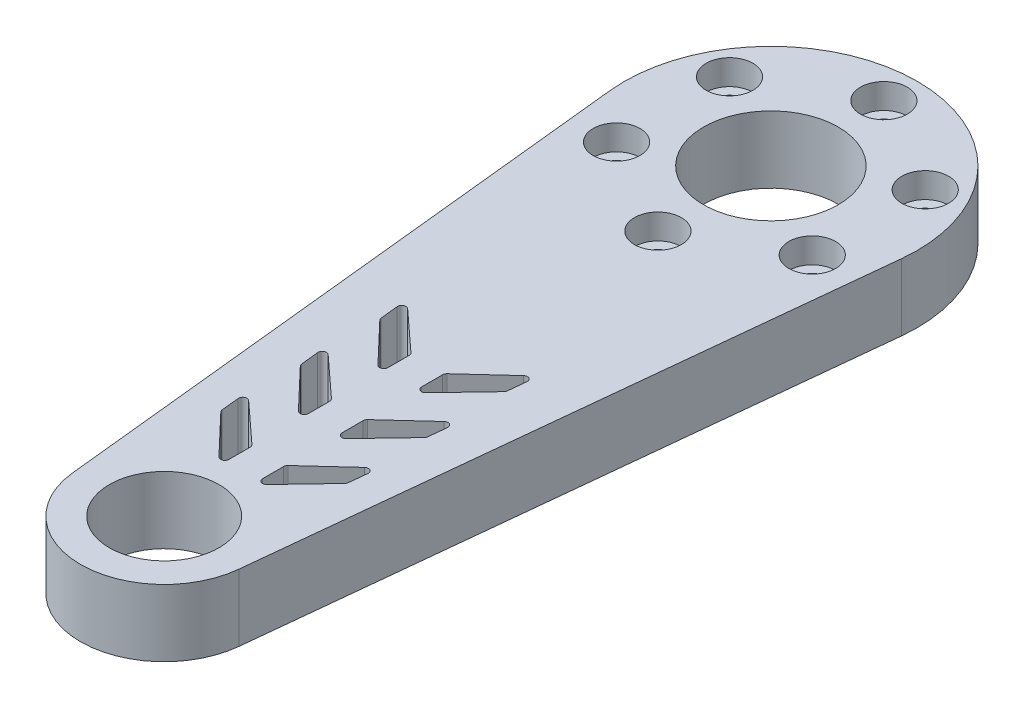
from build123d import *

# Parameters (mm, degrees)
EXTRUDE_1_DEPTH                = 8
CUT_EXTRUDE_1_DEPTH            = 9
CUT_EXTRUDE_2_DEPTH            = 9
CUT_EXTRUDE_3_DEPTH            = 9
CUT_EXTRUDE_4_DEPTH            = 9
CUT_EXTRUDE_5_DEPTH            = 9
CUT_EXTRUDE_6_DEPTH            = 9
HOLE_WIZARD_16_0_16_1_D        = 16.1
HOLE_WIZARD_16_0_16_1_DEPTH    = 8
HOLE_WIZARD_13_0_13_1_D        = 13.1
HOLE_WIZARD_13_0_13_1_DEPTH    = 8
HOLE_WIZARD_M2_5_1_D           = 3.1
HOLE_WIZARD_M2_5_1_DEPTH       = 8
HOLE_WIZARD_M2_5_1_CBORE_D     = 5.6
HOLE_WIZARD_M2_5_1_CBORE_DEPTH = 3
FILLET_1_R                     = 0.5


with BuildPart() as part:
    # 草图1 → 凸台-拉伸1 (new body)
    with BuildSketch(Plane(origin=(0, 4, 0), x_dir=(1, 0, 0), z_dir=(0, 1, 0))):
        with BuildLine():
            Line((-17.406109606, -1.810344828), (-9.946348346, -73.534482759))
            ThreePointArc((-9.946348346, -73.534482759), (0, -82.5), (9.946348346, -73.534482759))
            Line((9.946348346, -73.534482759), (17.406109606, -1.810344828))
            ThreePointArc((17.406109606, -1.810344828), (0, 17.5), (-17.406109606, -1.810344828))
        make_face()
    extrude(amount=-EXTRUDE_1_DEPTH)

    # 草图2 → 切除-拉伸1 (cut, through all)
    with BuildSketch(Plane(origin=(0, 4, 0), x_dir=(-1, 0, 0), z_dir=(0, 1, 0))):
        with BuildLine():
            Line((2, 43.750482659), (2, 41))
            Line((2, 41), (6.923179382, 36.483241979))
            ThreePointArc((6.923179382, 36.483241979), (7.485869271, 36.40499598), (7.758515386, 36.903399876))
            Line((7.758515386, 36.903399876), (7.518784371, 39.208366459))
            Line((7.518784371, 39.208366459), (2.861977096, 44.095406683))
            ThreePointArc((2.861977096, 44.095406683), (2.314242831, 44.214696268), (2, 43.750482659))
        make_face()
    extrude(amount=-CUT_EXTRUDE_1_DEPTH, mode=Mode.SUBTRACT)

    # 草图3 → 切除-拉伸2 (cut, through all)
    with BuildSketch(Plane(origin=(0, 4, 0), x_dir=(-1, 0, 0), z_dir=(0, 1, 0))):
        with BuildLine():
            Line((-6.923179382, 36.483241979), (-2, 41))
            Line((-2, 41), (-2, 43.750482659))
            ThreePointArc((-2, 43.750482659), (-2.314242831, 44.214696268), (-2.861977096, 44.095406683))
            Line((-2.861977096, 44.095406683), (-7.518784371, 39.208366459))
            Line((-7.518784371, 39.208366459), (-7.758515386, 36.903399876))
            ThreePointArc((-7.758515386, 36.903399876), (-7.485869271, 36.40499598), (-6.923179382, 36.483241979))
        make_face()
    extrude(amount=-CUT_EXTRUDE_2_DEPTH, mode=Mode.SUBTRACT)

    # 草图4 → 切除-拉伸3 (cut, through all)
    with BuildSketch(Plane(origin=(0, 4, 0), x_dir=(-1, 0, 0), z_dir=(0, 1, 0))):
        with BuildLine():
            Line((2, 53.250482659), (2, 50.5))
            Line((2, 50.5), (6.923179382, 45.983241979))
            ThreePointArc((6.923179382, 45.983241979), (7.485869271, 45.90499598), (7.758515386, 46.403399876))
            Line((7.758515386, 46.403399876), (7.518784371, 48.708366459))
            Line((7.518784371, 48.708366459), (2.861977096, 53.595406683))
            ThreePointArc((2.861977096, 53.595406683), (2.314242831, 53.714696268), (2, 53.250482659))
        make_face()
    extrude(amount=-CUT_EXTRUDE_3_DEPTH, mode=Mode.SUBTRACT)

    # 草图5 → 切除-拉伸4 (cut, through all)
    with BuildSketch(Plane(origin=(0, 4, 0), x_dir=(-1, 0, 0), z_dir=(0, 1, 0))):
        with BuildLine():
            Line((-6.923179382, 45.983241979), (-2, 50.5))
            Line((-2, 50.5), (-2, 53.250482659))
            ThreePointArc((-2, 53.250482659), (-2.314242831, 53.714696268), (-2.861977096, 53.595406683))
            Line((-2.861977096, 53.595406683), (-7.518784371, 48.708366459))
            Line((-7.518784371, 48.708366459), (-7.758515386, 46.403399876))
            ThreePointArc((-7.758515386, 46.403399876), (-7.485869271, 45.90499598), (-6.923179382, 45.983241979))
        make_face()
    extrude(amount=-CUT_EXTRUDE_4_DEPTH, mode=Mode.SUBTRACT)

    # 草图6 → 切除-拉伸5 (cut, through all)
    with BuildSketch(Plane(origin=(0, 4, 0), x_dir=(-1, 0, 0), z_dir=(0, 1, 0))):
        with BuildLine():
            Line((2, 62.750482659), (2, 60))
            Line((2, 60), (6.923179382, 55.483241979))
            ThreePointArc((6.923179382, 55.483241979), (7.485869271, 55.40499598), (7.758515386, 55.903399876))
            Line((7.758515386, 55.903399876), (7.518784371, 58.208366459))
            Line((7.518784371, 58.208366459), (2.861977096, 63.095406683))
            ThreePointArc((2.861977096, 63.095406683), (2.314242831, 63.214696268), (2, 62.750482659))
        make_face()
    extrude(amount=-CUT_EXTRUDE_5_DEPTH, mode=Mode.SUBTRACT)

    # 草图7 → 切除-拉伸6 (cut, through all)
    with BuildSketch(Plane.XZ.offset(4)):
        with BuildLine():
            Line((2, 62.750482659), (2, 60))
            Line((2, 60), (6.923179382, 55.483241979))
            ThreePointArc((6.923179382, 55.483241979), (7.485869271, 55.40499598), (7.758515386, 55.903399876))
            Line((7.758515386, 55.903399876), (7.518784371, 58.208366459))
            Line((7.518784371, 58.208366459), (2.861977096, 63.095406683))
            ThreePointArc((2.861977096, 63.095406683), (2.314242831, 63.214696268), (2, 62.750482659))
        make_face()
    extrude(amount=-CUT_EXTRUDE_6_DEPTH, mode=Mode.SUBTRACT)

    # Ø16.0 (16) 直径孔1
    with Locations(Plane(origin=(0, -4, 0), x_dir=(-1, 0, 0), z_dir=(0, -1, 0))):
        with Locations((0, 0)):
            Hole(HOLE_WIZARD_16_0_16_1_D / 2, depth=HOLE_WIZARD_16_0_16_1_DEPTH)

    # Ø13.0 (13) 直径孔1
    with Locations(Plane(origin=(0, 4, 0), x_dir=(1, 0, 0), z_dir=(0, 1, 0))):
        with Locations((0, -72.5)):
            Hole(HOLE_WIZARD_13_0_13_1_D / 2, depth=HOLE_WIZARD_13_0_13_1_DEPTH)

    # M2.5 六角头机械螺钉的柱形沉头孔1
    with Locations(Plane(origin=(0, 4, 0), x_dir=(1, 0, 0), z_dir=(0, 1, 0))):
        with Locations((-11.691342951, -6.75), (-11.691342951, 6.75), (0, 13.5), (11.691342951, 6.75), (11.691342951, -6.75), (0, -13.5)):
            CounterBoreHole(HOLE_WIZARD_M2_5_1_D / 2, HOLE_WIZARD_M2_5_1_CBORE_D / 2, HOLE_WIZARD_M2_5_1_CBORE_DEPTH, depth=HOLE_WIZARD_M2_5_1_DEPTH)

    # 圆角1
    fillet_1_edges = [part.edges().sort_by_distance(p)[0] for p in [
        (-7.518784371, 0, 58.208366459),
        (-2, 0, 60),
        (7.518784371, 0, 58.208366459),
        (2, 0, 60),
        (-7.518784371, 0, 39.208366459),
        (-2, 0, 41),
        (7.518784371, 0, 39.208366459),
        (2, 0, 41),
        (-7.518784371, 0, 48.708366459),
        (-2, 0, 50.5),
        (7.518784371, 0, 48.708366459),
        (2, 0, 50.5),
    ]]
    fillet(fillet_1_edges, radius=FILLET_1_R)


solid = part.part
